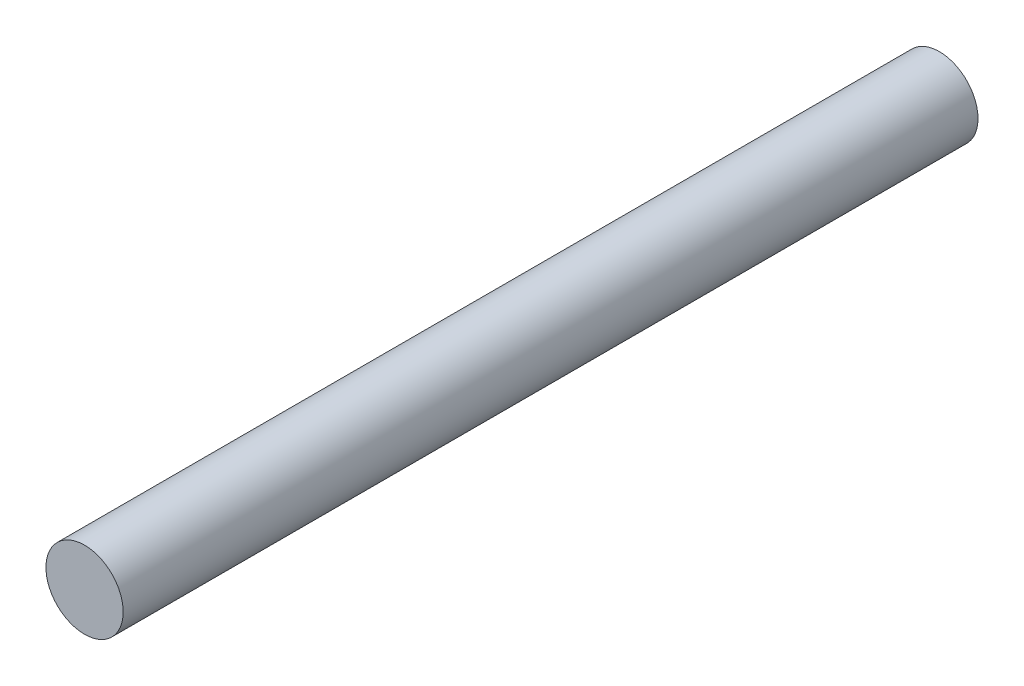
from build123d import *

# Parameters (mm, degrees)
SKETCH1_R      = 1.2065
EXTRUDE1_DEPTH = 26.6954


with BuildPart() as part:
    # Sketch1 → Extrude1 (new body)
    with BuildSketch(Plane.XY):
        Circle(SKETCH1_R)
    extrude(amount=EXTRUDE1_DEPTH)


solid = part.part
